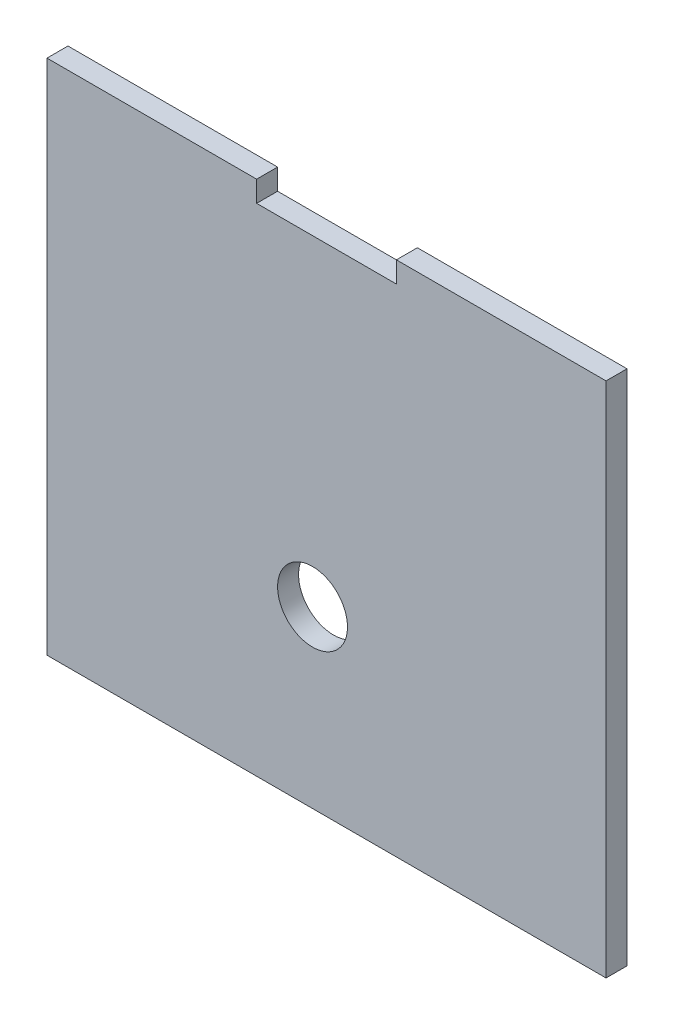
from build123d import *

# Parameters (mm, degrees)
ESBO_O2_R                = 5
RESSALTO_EXTRUS_O1_DEPTH = 3


with BuildPart() as part:
    # Esboço2 → Ressalto-extrusão1 (new body)
    with BuildSketch(Plane.XY):
        Polygon((3, -22.847071625), (3, 51.152928375), (-27, 51.152928375), (-27, 48.152928375), (-47, 48.152928375), (-47, 51.152928375), (-77, 51.152928375), (-77, -22.847071625), align=None)
        with Locations((-39, 2.152928375)):
            Circle(ESBO_O2_R, mode=Mode.SUBTRACT)
    extrude(amount=RESSALTO_EXTRUS_O1_DEPTH)


solid = part.part
